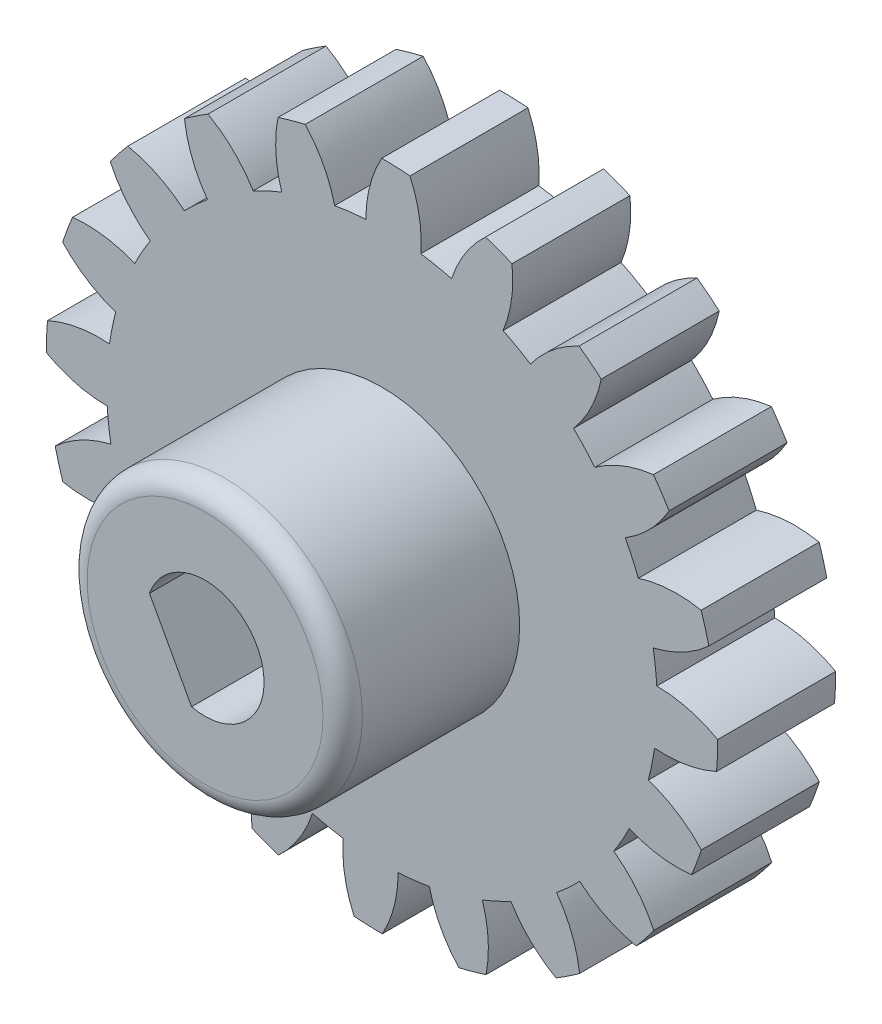
from build123d import *

# Parameters (mm, degrees)
EXTRUDE_4_DEPTH     = 3
SKETCH_5_R          = 3.5
EXTRUDE_6_DEPTH     = 4.5
FILLET_1_R          = 0.5
CUT_EXTRUDE_1_DEPTH = 8.5


with BuildPart() as part:
    # 草图4 → 凸台-拉伸4 (new body)
    with BuildSketch(Plane.XY):
        with BuildLine():
            ThreePointArc((8.536063079, 0.007574004), (7.787120491, 0.307636704), (6.986931627, 0.410837493))
            ThreePointArc((6.986931627, 0.410837493), (6.952112765, 0.808782481), (6.894647301, 1.204092849))
            ThreePointArc((6.894647301, 1.204092849), (7.649774364, 1.488233206), (8.309831075, 1.95221355))
            ThreePointArc((8.309831075, 1.95221355), (8.220185959, 2.300646222), (8.115937918, 2.644991862))
            ThreePointArc((8.115937918, 2.644991862), (7.310926717, 2.698932461), (6.518011085, 2.549810286))
            ThreePointArc((6.518011085, 2.549810286), (6.361924616, 2.91751884), (6.18511409, 3.275723537))
            ThreePointArc((6.18511409, 3.275723537), (6.815478405, 3.77930417), (7.29985183, 4.424544441))
            ThreePointArc((7.29985183, 4.424544441), (7.106922641, 4.72822174), (6.901368208, 5.023499488))
            ThreePointArc((6.901368208, 5.023499488), (6.119088497, 4.826037904), (5.411062205, 4.439189883))
            ThreePointArc((5.411062205, 4.439189883), (5.148986959, 4.740668128), (4.870138818, 5.026703581))
            ThreePointArc((4.870138818, 5.026703581), (5.314035933, 5.70043051), (5.575312226, 6.463770094))
            ThreePointArc((5.575312226, 6.463770094), (5.297984218, 6.69296597), (5.011244492, 6.910271984))
            ThreePointArc((5.011244492, 6.910271984), (4.328271261, 6.480737132), (3.774440855, 5.894030644))
            ThreePointArc((3.774440855, 5.894030644), (3.432030584, 6.099767788), (3.078440426, 6.285634856))
            ThreePointArc((3.078440426, 6.285634856), (3.292418599, 7.063558994), (3.305022217, 7.870276894))
            ThreePointArc((3.305022217, 7.870276894), (2.970442186, 8.002556058), (2.63058525, 8.12061891))
            ThreePointArc((2.63058525, 8.12061891), (2.113772678, 7.501056656), (1.768350936, 6.77192262))
            ThreePointArc((1.768350936, 6.77192262), (1.379123142, 6.861779679), (0.985402836, 6.929284397))
            ThreePointArc((0.985402836, 6.929284397), (0.948516393, 7.735257109), (0.711213605, 8.506386157))
            ThreePointArc((0.711213605, 8.506386157), (0.352132577, 8.528800203), (-0.007574004, 8.536063079))
            ThreePointArc((-0.007574004, 8.536063079), (-0.307636703, 7.787120491), (-0.410837493, 6.986931627))
            ThreePointArc((-0.410837493, 6.986931627), (-0.808782481, 6.952112765), (-1.204092849, 6.894647301))
            ThreePointArc((-1.204092849, 6.894647301), (-1.488233206, 7.649774364), (-1.95221355, 8.309831075))
            ThreePointArc((-1.95221355, 8.309831075), (-2.300646222, 8.220185959), (-2.644991862, 8.115937918))
            ThreePointArc((-2.644991862, 8.115937918), (-2.698932461, 7.310926717), (-2.549810286, 6.518011085))
            ThreePointArc((-2.549810286, 6.518011085), (-2.91751884, 6.361924616), (-3.275723537, 6.18511409))
            ThreePointArc((-3.275723537, 6.18511409), (-3.77930417, 6.815478405), (-4.424544441, 7.29985183))
            ThreePointArc((-4.424544441, 7.29985183), (-4.72822174, 7.106922641), (-5.023499488, 6.901368208))
            ThreePointArc((-5.023499488, 6.901368208), (-4.826037904, 6.119088497), (-4.439189882, 5.411062205))
            ThreePointArc((-4.439189882, 5.411062205), (-4.740668128, 5.148986959), (-5.026703581, 4.870138818))
            ThreePointArc((-5.026703581, 4.870138818), (-5.70043051, 5.314035933), (-6.463770094, 5.575312226))
            ThreePointArc((-6.463770094, 5.575312226), (-6.69296597, 5.297984218), (-6.910271984, 5.011244492))
            ThreePointArc((-6.910271984, 5.011244492), (-6.480737132, 4.328271262), (-5.894030644, 3.774440855))
            ThreePointArc((-5.894030644, 3.774440855), (-6.099767788, 3.432030584), (-6.285634856, 3.078440426))
            ThreePointArc((-6.285634856, 3.078440426), (-7.063558994, 3.292418599), (-7.870276894, 3.305022217))
            ThreePointArc((-7.870276894, 3.305022217), (-8.002556058, 2.970442186), (-8.12061891, 2.63058525))
            ThreePointArc((-8.12061891, 2.63058525), (-7.501056656, 2.113772678), (-6.77192262, 1.768350936))
            ThreePointArc((-6.77192262, 1.768350936), (-6.861779679, 1.379123142), (-6.929284397, 0.985402836))
            ThreePointArc((-6.929284397, 0.985402836), (-7.735257109, 0.948516393), (-8.506386157, 0.711213605))
            ThreePointArc((-8.506386157, 0.711213605), (-8.528800203, 0.352132577), (-8.536063079, -0.007574004))
            ThreePointArc((-8.536063079, -0.007574004), (-7.787120492, -0.307636703), (-6.986931627, -0.410837493))
            ThreePointArc((-6.986931627, -0.410837493), (-6.952112765, -0.808782481), (-6.894647301, -1.204092849))
            ThreePointArc((-6.894647301, -1.204092849), (-7.649774364, -1.488233206), (-8.309831076, -1.95221355))
            ThreePointArc((-8.309831076, -1.95221355), (-8.220185959, -2.300646222), (-8.115937918, -2.644991862))
            ThreePointArc((-8.115937918, -2.644991862), (-7.310926717, -2.698932461), (-6.518011085, -2.549810286))
            ThreePointArc((-6.518011085, -2.549810286), (-6.361924616, -2.91751884), (-6.18511409, -3.275723537))
            ThreePointArc((-6.18511409, -3.275723537), (-6.815478405, -3.77930417), (-7.29985183, -4.424544441))
            ThreePointArc((-7.29985183, -4.424544441), (-7.106922641, -4.72822174), (-6.901368208, -5.023499488))
            ThreePointArc((-6.901368208, -5.023499488), (-6.119088498, -4.826037904), (-5.411062205, -4.439189883))
            ThreePointArc((-5.411062205, -4.439189883), (-5.148986959, -4.740668128), (-4.870138818, -5.026703582))
            ThreePointArc((-4.870138818, -5.026703582), (-5.314035933, -5.70043051), (-5.575312227, -6.463770094))
            ThreePointArc((-5.575312227, -6.463770094), (-5.297984218, -6.69296597), (-5.011244492, -6.910271984))
            ThreePointArc((-5.011244492, -6.910271984), (-4.328271262, -6.480737132), (-3.774440855, -5.894030644))
            ThreePointArc((-3.774440855, -5.894030644), (-3.432030584, -6.099767789), (-3.078440426, -6.285634856))
            ThreePointArc((-3.078440426, -6.285634856), (-3.292418599, -7.063558994), (-3.305022217, -7.870276894))
            ThreePointArc((-3.305022217, -7.870276894), (-2.970442186, -8.002556058), (-2.63058525, -8.12061891))
            ThreePointArc((-2.63058525, -8.12061891), (-2.113772678, -7.501056656), (-1.768350936, -6.77192262))
            ThreePointArc((-1.768350936, -6.77192262), (-1.379123142, -6.861779679), (-0.985402836, -6.929284397))
            ThreePointArc((-0.985402836, -6.929284397), (-0.948516393, -7.735257109), (-0.711213605, -8.506386157))
            ThreePointArc((-0.711213605, -8.506386157), (-0.352132577, -8.528800203), (0.007574004, -8.536063079))
            ThreePointArc((0.007574004, -8.536063079), (0.307636704, -7.787120491), (0.410837493, -6.986931627))
            ThreePointArc((0.410837493, -6.986931627), (0.808782481, -6.952112765), (1.204092849, -6.894647301))
            ThreePointArc((1.204092849, -6.894647301), (1.488233206, -7.649774364), (1.95221355, -8.309831075))
            ThreePointArc((1.95221355, -8.309831075), (2.300646222, -8.220185959), (2.644991862, -8.115937918))
            ThreePointArc((2.644991862, -8.115937918), (2.698932461, -7.310926717), (2.549810286, -6.518011085))
            ThreePointArc((2.549810286, -6.518011085), (2.91751884, -6.361924616), (3.275723537, -6.18511409))
            ThreePointArc((3.275723537, -6.18511409), (3.77930417, -6.815478405), (4.424544441, -7.29985183))
            ThreePointArc((4.424544441, -7.29985183), (4.72822174, -7.106922641), (5.023499488, -6.901368208))
            ThreePointArc((5.023499488, -6.901368208), (4.826037904, -6.119088497), (4.439189883, -5.411062205))
            ThreePointArc((4.439189883, -5.411062205), (4.740668128, -5.148986959), (5.026703582, -4.870138818))
            ThreePointArc((5.026703582, -4.870138818), (5.70043051, -5.314035933), (6.463770094, -5.575312226))
            ThreePointArc((6.463770094, -5.575312226), (6.69296597, -5.297984218), (6.910271984, -5.011244492))
            ThreePointArc((6.910271984, -5.011244492), (6.480737132, -4.328271261), (5.894030644, -3.774440855))
            ThreePointArc((5.894030644, -3.774440855), (6.099767788, -3.432030584), (6.285634856, -3.078440425))
            ThreePointArc((6.285634856, -3.078440425), (7.063558994, -3.292418599), (7.870276894, -3.305022217))
            ThreePointArc((7.870276894, -3.305022217), (8.002556058, -2.970442186), (8.12061891, -2.63058525))
            ThreePointArc((8.12061891, -2.63058525), (7.501056656, -2.113772678), (6.77192262, -1.768350936))
            ThreePointArc((6.77192262, -1.768350936), (6.861779679, -1.379123142), (6.929284397, -0.985402836))
            ThreePointArc((6.929284397, -0.985402836), (7.735257109, -0.948516393), (8.506386157, -0.711213605))
            ThreePointArc((8.506386157, -0.711213605), (8.528643141, -0.355916321), (8.536066439, 0))
            ThreePointArc((8.536066439, 0), (8.536065599, 0.003787002), (8.536063079, 0.007574004))
        make_face()
    extrude(amount=EXTRUDE_4_DEPTH)

    # 草图5 → 凸台-拉伸6 (add)
    with BuildSketch(Plane.XY.offset(3)):
        Circle(SKETCH_5_R)
    extrude(amount=EXTRUDE_6_DEPTH)

    # 圆角1
    fillet_1_edges = [part.edges().sort_by_distance(p)[0] for p in [
        (-3.5, 0, 7.5),
    ]]
    fillet(fillet_1_edges, radius=FILLET_1_R)

    # 草图8 → 切除-拉伸1 (cut, through all)
    with BuildSketch(Plane(origin=(0, 0, 0), x_dir=(-1, 0, 0), z_dir=(0, 0, -1))):
        with BuildLine():
            Line((0.342458427, -1.460384273), (1.413290623, 0.50260284))
            ThreePointArc((1.413290623, 0.50260284), (-1.316811787, 0.718336075), (0.342458427, -1.460384273))
        make_face()
    extrude(amount=-CUT_EXTRUDE_1_DEPTH, mode=Mode.SUBTRACT)


solid = part.part
